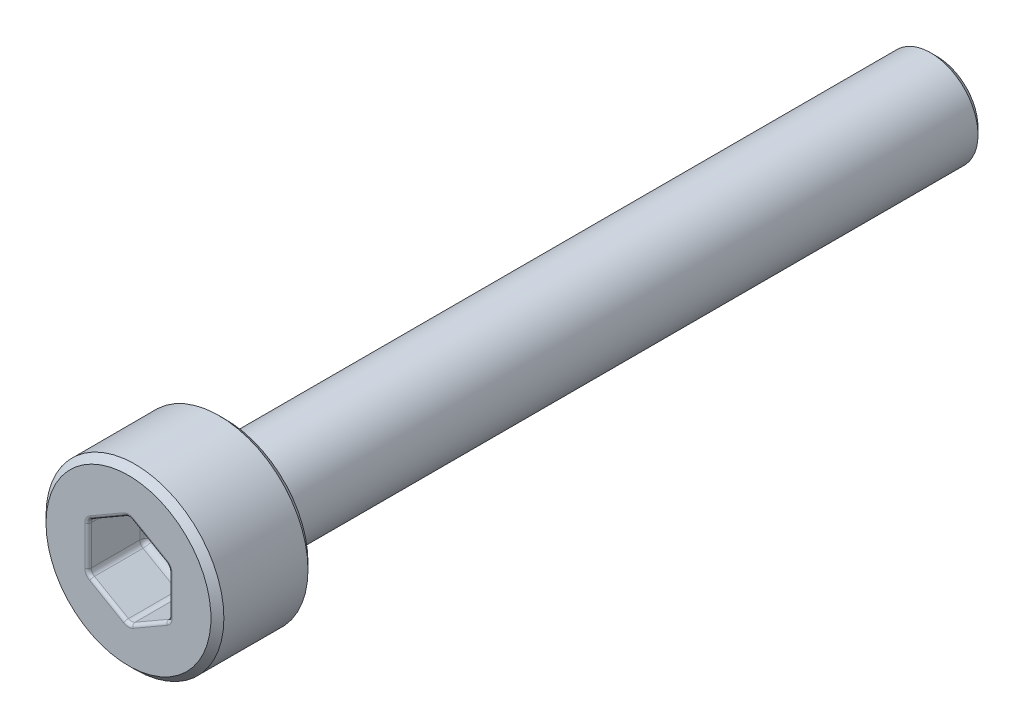
from build123d import *

# Parameters (mm, degrees)
SCHNITT_LINEAR_AUSTRAGEN1_DEPTH = 1.8
FASE1_SIZE                      = 0.2
VERRUNDUNG1_R                   = 0.2
VERRUNDUNG2_R                   = 0.1


with BuildPart() as part:
    # Skizze1 → Rotation1 (revolve)
    with BuildSketch(Plane(origin=(0, 0, 0), x_dir=(0, 0, -1), z_dir=(1, 0, 0))):
        Polygon((-3, 0), (-3, 2.75), (0, 2.75), (0, 1.465), (22, 1.465), (22, 0), align=None)
    revolve(axis=Axis((0, 0, 21.919879518), (0, 0, -1)))

    # Skizze2 → Schnitt-Linear austragen1 (cut)
    with BuildSketch(Plane.XY.offset(3)):
        Polygon((1.25, -0.721687836), (1.25, 0.721687836), (0, 1.443375673), (-1.25, 0.721687836), (-1.25, -0.721687836), (0, -1.443375673), align=None)
    extrude(amount=-SCHNITT_LINEAR_AUSTRAGEN1_DEPTH, mode=Mode.SUBTRACT)

    # Fase1
    fase1_edges = [part.edges().sort_by_distance(p)[0] for p in [
        (0, -1.465, -22),
        (0, -2.75, 0),
        (0, -2.75, 3),
    ]]
    chamfer(fase1_edges, length=FASE1_SIZE)

    # Verrundung1
    verrundung1_edges = [part.edges().sort_by_distance(p)[0] for p in [
        (0.625, -1.082531755, 1.2),
        (1.25, -0.721687836, 2.1),
        (-0.625, -1.082531755, 1.2),
        (0, -1.443375673, 2.1),
        (-1.25, 0, 1.2),
        (-1.25, -0.721687836, 2.1),
        (-0.625, 1.082531755, 1.2),
        (-1.25, 0.721687836, 2.1),
        (0.625, 1.082531755, 1.2),
        (0, 1.443375673, 2.1),
        (1.25, 0, 1.2),
        (1.25, 0.721687836, 2.1),
        (0, -1.465, 0),
    ]]
    fillet(verrundung1_edges, radius=VERRUNDUNG1_R)

    # Verrundung2
    verrundung2_edges = [part.edges().sort_by_distance(p)[0] for p in [
        (-0.625, -1.082531755, 3),
        (-1.25, 0, 3),
        (-0.625, 1.082531755, 3),
        (0.625, 1.082531755, 3),
        (1.25, 0, 3),
        (0.625, -1.082531755, 3),
        (-1.223205081, -0.706217783, 3),
        (0, -1.412435565, 3),
        (1.223205081, -0.706217783, 3),
        (1.223205081, 0.706217783, 3),
        (0, 1.412435565, 3),
        (-1.223205081, 0.706217783, 3),
    ]]
    fillet(verrundung2_edges, radius=VERRUNDUNG2_R)


solid = part.part
